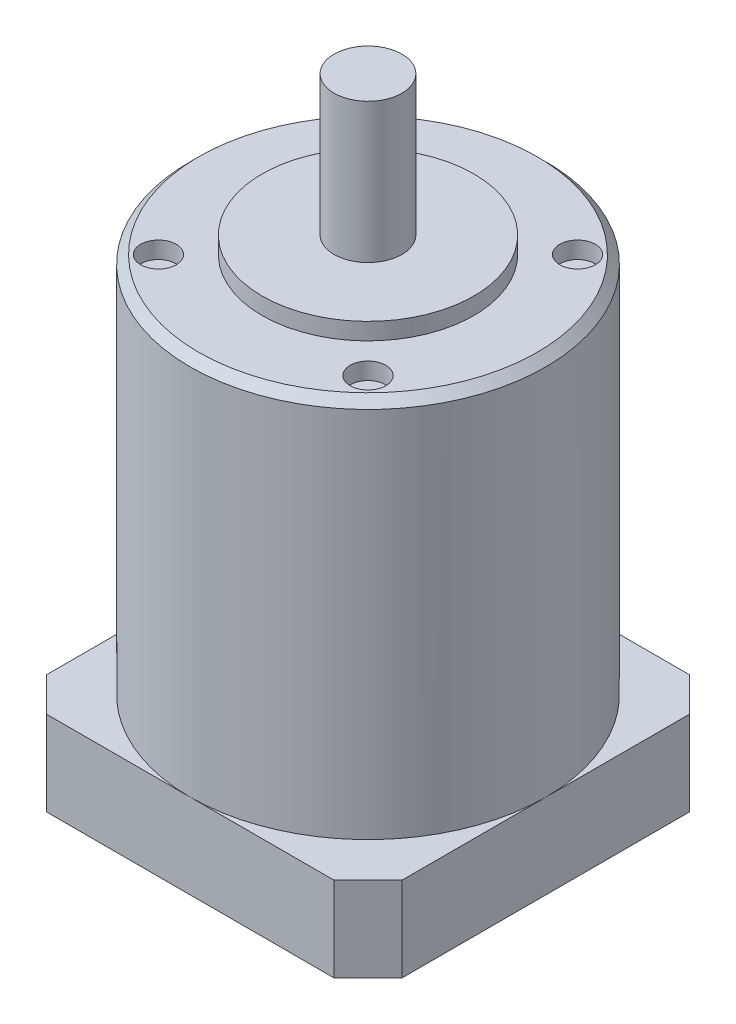
from build123d import *

# Parameters (mm, degrees)
SKETCH_1_W               = 42
SKETCH_1_H               = 42
EXTRUDE_1_DEPTH          = 10
SKETCH_2_R               = 21
EXTRUDE_2_DEPTH          = 45
SKETCH_3_R               = 4
EXTRUDE_3_DEPTH          = 18.5
CHAMFER_1_SIZE           = 4
SKETCH_4_R               = 11
CUT_EXTRUDE_1_DEPTH      = 25
SKETCH_5_R               = 12.5
EXTRUDE_4_DEPTH          = 2
CHAMFER_2_SIZE           = 1
SKETCH_6_R               = 2.1
CUT_EXTRUDE_2_DEPTH      = 2
PATTERN_CIRCULAR_1_COUNT = 4
SKETCH_7_R               = 2.1
CUT_EXTRUDE_3_DEPTH      = 8
PATTERN_CIRCULAR_2_COUNT = 4


with BuildPart() as part:
    # 草圖1 → 填料-伸長1 (new body)
    with BuildSketch(Plane(origin=(0, 0, 0), x_dir=(1, 0, 0), z_dir=(0, 1, 0))):
        Rectangle(SKETCH_1_W, SKETCH_1_H)
    extrude(amount=EXTRUDE_1_DEPTH)

    # 草圖2 → 填料-伸長2 (add)
    with BuildSketch(Plane(origin=(0, 10, 0), x_dir=(1, 0, 0), z_dir=(0, 1, 0))):
        Circle(SKETCH_2_R)
    extrude(amount=EXTRUDE_2_DEPTH)

    # 草圖3 → 填料-伸長3 (add)
    with BuildSketch(Plane(origin=(0, 55, 0), x_dir=(1, 0, 0), z_dir=(0, 1, 0))):
        Circle(SKETCH_3_R)
    extrude(amount=EXTRUDE_3_DEPTH)

    # 導角1
    chamfer_1_edges = [part.edges().sort_by_distance(p)[0] for p in [
        (21, 5, 21),
        (-21, 5, 21),
        (-21, 5, -21),
        (21, 5, -21),
    ]]
    chamfer(chamfer_1_edges, length=CHAMFER_1_SIZE)

    # 草圖4 → 除料-伸長1 (cut)
    with BuildSketch(Plane.XZ):
        Circle(SKETCH_4_R)
    extrude(amount=-CUT_EXTRUDE_1_DEPTH, mode=Mode.SUBTRACT)

    # 草圖5 → 填料-伸長4 (add)
    with BuildSketch(Plane(origin=(0, 55, 0), x_dir=(1, 0, 0), z_dir=(0, 1, 0))):
        Circle(SKETCH_5_R)
    extrude(amount=EXTRUDE_4_DEPTH)

    # 導角2
    chamfer_2_edges = [part.edges().sort_by_distance(p)[0] for p in [
        (-21, 55, 0),
    ]]
    chamfer(chamfer_2_edges, length=CHAMFER_2_SIZE)

    # 草圖6 → 除料-伸長2 (cut)
    with BuildSketch(Plane(origin=(0, 55, 0), x_dir=(1, 0, 0), z_dir=(0, 1, 0))):
        with Locations((-12.374368671, 12.374368671)):
            Circle(SKETCH_6_R)
    cut_extrude_2 = extrude(amount=-CUT_EXTRUDE_2_DEPTH, mode=Mode.SUBTRACT)

    # 環狀複製排列1: 除料-伸長2 ×4 about axis
    pattern_circular_1_axis = Axis((0, 0, 0), (0, 1, 0))
    for i in range(1, PATTERN_CIRCULAR_1_COUNT):
        add(cut_extrude_2.rotate(pattern_circular_1_axis, i * 360 / PATTERN_CIRCULAR_1_COUNT), mode=Mode.SUBTRACT)

    # 草圖7 → 除料-伸長3 (cut)
    with BuildSketch(Plane.XZ):
        with Locations((-15.5, 15.5)):
            Circle(SKETCH_7_R)
    cut_extrude_3 = extrude(amount=-CUT_EXTRUDE_3_DEPTH, mode=Mode.SUBTRACT)

    # 環狀複製排列2: 除料-伸長3 ×4 about axis
    pattern_circular_2_axis = Axis((0, 0, 0), (0, 1, 0))
    for i in range(1, PATTERN_CIRCULAR_2_COUNT):
        add(cut_extrude_3.rotate(pattern_circular_2_axis, i * 360 / PATTERN_CIRCULAR_2_COUNT), mode=Mode.SUBTRACT)


solid = part.part
